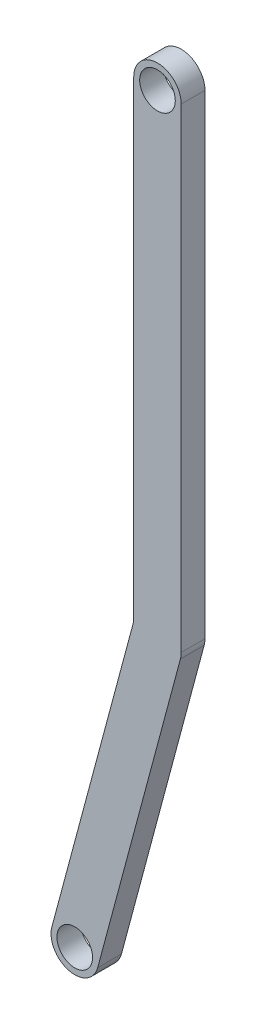
from build123d import *

# Parameters (mm, degrees)
SKETCH1_R           = 0.75
BOSS_EXTRUDE1_DEPTH = 1


with BuildPart() as part:
    # Sketch1 → Boss-Extrude1 (new body)
    with BuildSketch(Plane.XY):
        with BuildLine():
            Line((-2.517413675, -33.258819045), (0.965925826, -20.258819045))
            ThreePointArc((0.965925826, -20.258819045), (-0.130526192, -20.991444861), (-1, -20))
            Line((-1, -20), (-1, -19.868347502))
            Line((-1, -19.868347502), (-4.449265328, -32.741180955))
            ThreePointArc((-4.449265328, -32.741180955), (-3.742158547, -33.965925826), (-2.517413675, -33.258819045))
        make_face()
        with Locations((-3.483339502, -33)):
            Circle(SKETCH1_R, mode=Mode.SUBTRACT)
        with BuildLine():
            ThreePointArc((0.965925826, -20.258819045), (0.991444861, -20.130526192), (1, -20))
            ThreePointArc((1, -20), (0.130526192, -19.008555139), (-0.965925826, -19.741180955))
            Line((-0.965925826, -19.741180955), (-1, -19.868347502))
            Line((-1, -19.868347502), (-1, -20))
            ThreePointArc((-1, -20), (-0.130526192, -20.991444861), (0.965925826, -20.258819045))
        make_face()
        with BuildLine():
            Line((1, -20), (1, 0))
            ThreePointArc((1, 0), (0, 1), (-1, 0))
            Line((-1, 0), (-1, -19.868347502))
            Line((-1, -19.868347502), (-0.965925826, -19.741180955))
            ThreePointArc((-0.965925826, -19.741180955), (0.130526192, -19.008555139), (1, -20))
        make_face()
        Circle(SKETCH1_R, mode=Mode.SUBTRACT)
    extrude(amount=BOSS_EXTRUDE1_DEPTH)


solid = part.part
